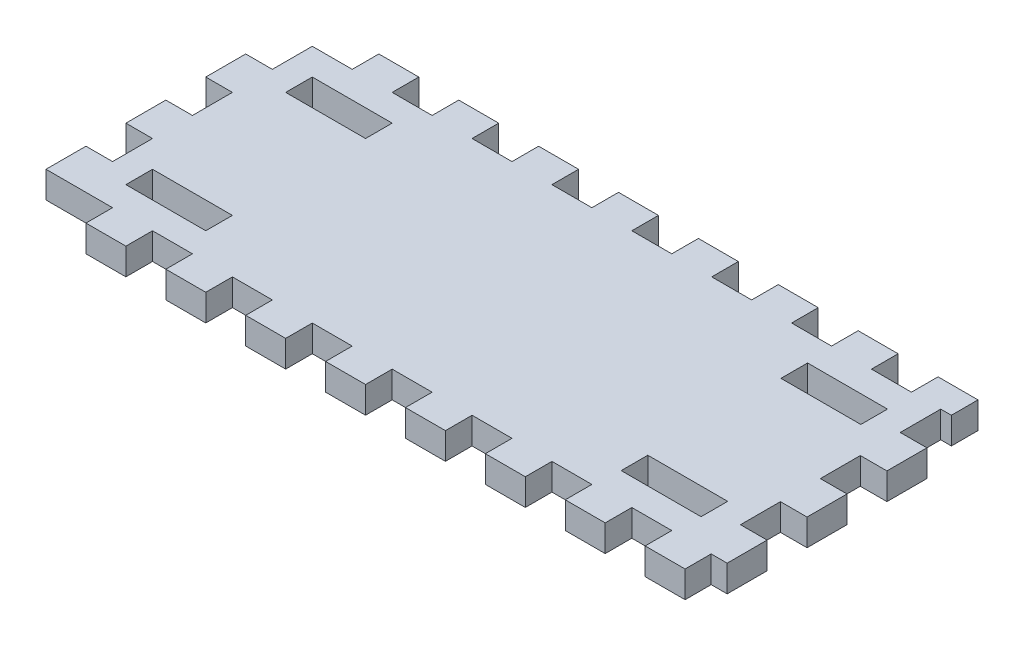
from build123d import *

# Parameters (mm, degrees)
SKETCH1_W           = 149.86
SKETCH1_H           = 57.15
SKETCH1_W_2         = 19.05
SKETCH1_H_2         = 6.35
BOSS_EXTRUDE1_DEPTH = 6.35
SKETCH2_W           = 6.35
SKETCH2_H           = 9.525
SKETCH2_W_2         = 9.525
SKETCH2_H_2         = 6.35
BOSS_EXTRUDE2_DEPTH = 6.35


with BuildPart() as part:
    # Sketch1 → Boss-Extrude1 (new body)
    with BuildSketch(Plane(origin=(0, 0, 0), x_dir=(1, 0, 0), z_dir=(0, 1, 0))):
        with Locations((74.93, -28.575)):
            Rectangle(SKETCH1_W, SKETCH1_H)
        with Locations((15.875, -47.625)):
            Rectangle(SKETCH1_W_2, SKETCH1_H_2, mode=Mode.SUBTRACT)
        with Locations((15.875, -9.525)):
            Rectangle(SKETCH1_W_2, SKETCH1_H_2, mode=Mode.SUBTRACT)
        with Locations((133.985, -47.625)):
            Rectangle(SKETCH1_W_2, SKETCH1_H_2, mode=Mode.SUBTRACT)
        with Locations((133.985, -9.525)):
            Rectangle(SKETCH1_W_2, SKETCH1_H_2, mode=Mode.SUBTRACT)
    extrude(amount=BOSS_EXTRUDE1_DEPTH)

    # Sketch2 → Boss-Extrude2 (add)
    with BuildSketch(Plane.XZ):
        with Locations((-3.175, 14.2875)):
            Rectangle(SKETCH2_W, SKETCH2_H)
        with Locations((-3.175, 33.3375)):
            Rectangle(SKETCH2_W, SKETCH2_H)
        with Locations((-3.175, 52.3875)):
            Rectangle(SKETCH2_W, SKETCH2_H)
        with Locations((153.035, 14.4145)):
            Rectangle(SKETCH2_W, SKETCH2_H)
        with Locations((33.3375, 60.325)):
            Rectangle(SKETCH2_W_2, SKETCH2_H_2)
        with Locations((14.2875, 60.325)):
            Rectangle(SKETCH2_W_2, SKETCH2_H_2)
        with Locations((52.3875, 60.325)):
            Rectangle(SKETCH2_W_2, SKETCH2_H_2)
        with Locations((71.4375, 60.325)):
            Rectangle(SKETCH2_W_2, SKETCH2_H_2)
        with Locations((90.4875, 60.325)):
            Rectangle(SKETCH2_W_2, SKETCH2_H_2)
        with Locations((109.5375, 60.325)):
            Rectangle(SKETCH2_W_2, SKETCH2_H_2)
        with Locations((128.5875, 60.325)):
            Rectangle(SKETCH2_W_2, SKETCH2_H_2)
        Polygon((142.875, 63.5), (142.875, 57.15), (149.86, 57.15), (149.86, 47.752), (156.21, 47.752), (156.21, 57.277), (152.4, 57.277), (152.4, 63.5), align=None)
        with Locations((14.2875, -3.175)):
            Rectangle(SKETCH2_W_2, SKETCH2_H_2)
        with Locations((147.6375, -3.175)):
            Rectangle(SKETCH2_W_2, SKETCH2_H_2)
        with Locations((128.5875, -3.175)):
            Rectangle(SKETCH2_W_2, SKETCH2_H_2)
        with Locations((109.5375, -3.175)):
            Rectangle(SKETCH2_W_2, SKETCH2_H_2)
        with Locations((90.4875, -3.175)):
            Rectangle(SKETCH2_W_2, SKETCH2_H_2)
        with Locations((71.4375, -3.175)):
            Rectangle(SKETCH2_W_2, SKETCH2_H_2)
        with Locations((52.3875, -3.175)):
            Rectangle(SKETCH2_W_2, SKETCH2_H_2)
        with Locations((33.3375, -3.175)):
            Rectangle(SKETCH2_W_2, SKETCH2_H_2)
        with Locations((153.035, 33.4645)):
            Rectangle(SKETCH2_W, SKETCH2_H)
    extrude(amount=-BOSS_EXTRUDE2_DEPTH)


solid = part.part
